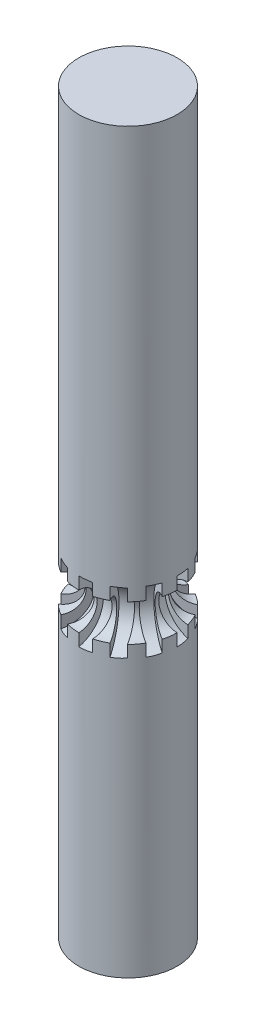
from build123d import *

# Parameters (mm, degrees)
ESQUISSE1_R             = 4
BOSS_EXTRU_1_DEPTH      = 60
ENL_V_MAT_EXTRU_2_DEPTH = 1
R_P_T_PAR_COURBE1_COUNT = 12
ESQUISSE5_R             = 1.5


with BuildPart() as part:
    # Esquisse1 → Boss.-Extru.1 (new body)
    with BuildSketch(Plane(origin=(0, 0, 0), x_dir=(1, 0, 0), z_dir=(0, 1, 0))):
        with Locations(Location((0, 0, 0), (0, 0, 270))):
            Circle(ESQUISSE1_R)
    extrude(amount=BOSS_EXTRU_1_DEPTH)

    # Esquisse4 → Enlèv. mat.-Extru.2 (cut)
    with BuildSketch(Plane.XY):
        with BuildLine():
            Line((4, 27.5), (4, 22.5))
            ThreePointArc((4, 22.5), (2, 25), (4, 27.5))
        make_face()
    enl_v_mat_extru_2 = extrude(amount=-ENL_V_MAT_EXTRU_2_DEPTH, mode=Mode.SUBTRACT)

    # Répét. par courbe1: Enlèv. mat.-Extru.2 ×12 about axis
    r_p_t_par_courbe1_axis = Axis((0, 25, 0), (0, -1, 0))
    for i in range(1, R_P_T_PAR_COURBE1_COUNT):
        add(enl_v_mat_extru_2.rotate(r_p_t_par_courbe1_axis, i * 360 / R_P_T_PAR_COURBE1_COUNT), mode=Mode.SUBTRACT)

    # Enlèvement de matière-Balayage1: sweep along a path in Esquisse3
    with BuildLine(Plane(origin=(0, 25, 0), x_dir=(1, 0, 0), z_dir=(0, 1, 0))) as enl_vement_de_mati_re_balayage1_path:
        CenterArc((0, 0), 4, 0, 360)
    # Esquisse5 → Enlèvement de matière-Balayage1 (sweep, cut)
    with BuildSketch(Plane(origin=(0, 0, 0), x_dir=(0, 0, -1), z_dir=(1, 0, 0))):
        with Locations((-4, 25)):
            Circle(ESQUISSE5_R)
    sweep(path=enl_vement_de_mati_re_balayage1_path.line, mode=Mode.SUBTRACT)


solid = part.part
